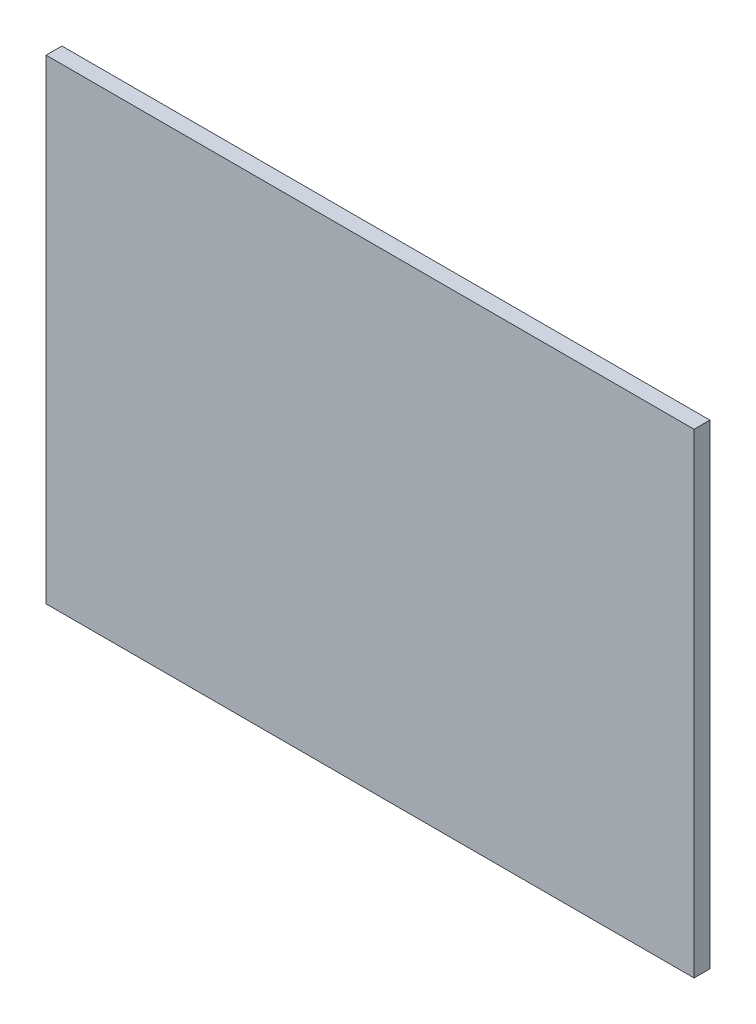
from build123d import *

# Parameters (mm, degrees)
ESQUISSE1_W        = 204.530112698
ESQUISSE1_H        = 150
BOSS_EXTRU_1_DEPTH = 5


with BuildPart() as part:
    # Esquisse1 → Boss.-Extru.1 (new body)
    with BuildSketch(Plane.XY):
        with Locations((102.265056349, 75)):
            Rectangle(ESQUISSE1_W, ESQUISSE1_H)
    extrude(amount=BOSS_EXTRU_1_DEPTH)


solid = part.part
